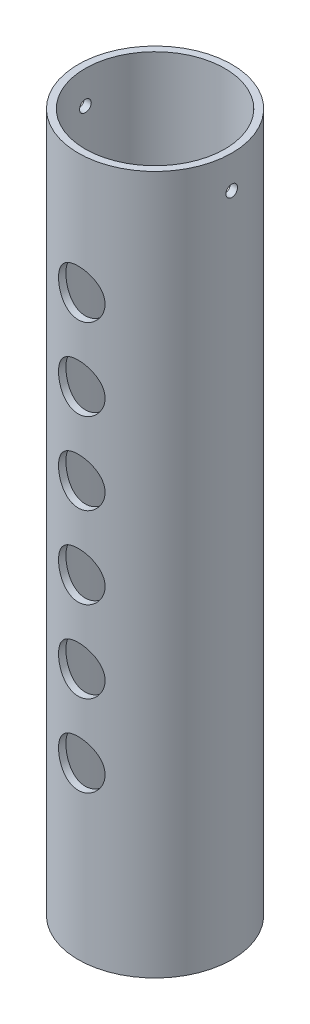
from build123d import *

# Parameters (mm, degrees)
SKETCH1_R               = 33
SKETCH1_R_2             = 30
EXTRUDE_THIN1_DEPTH     = 300
SKETCH2_R               = 10
CUT_EXTRUDE1_DEPTH      = 34
LPATTERN1_COUNT         = 6
LPATTERN1_PITCH         = 35
SKETCH3_R               = 2.5
CUT_EXTRUDE2_DEPTH      = 34.0000001
CUT_EXTRUDE2_DEPTH_BACK = 34.0000001


with BuildPart() as part:
    # Sketch1 → Extrude-Thin1 (new body)
    with BuildSketch(Plane(origin=(0, 0, 0), x_dir=(1, 0, 0), z_dir=(0, 1, 0))):
        Circle(SKETCH1_R)
        Circle(SKETCH1_R_2, mode=Mode.SUBTRACT)
    extrude(amount=EXTRUDE_THIN1_DEPTH)

    # Sketch2 → Cut-Extrude1 (cut, symmetric)
    with BuildSketch(Plane.XY):
        with Locations((0, 248)):
            Circle(SKETCH2_R)
    cut_extrude1 = extrude(amount=CUT_EXTRUDE1_DEPTH, both=True, mode=Mode.SUBTRACT)

    # LPattern1: Cut-Extrude1 ×6
    with Locations(*[(0, -i * LPATTERN1_PITCH, 0) for i in range(1, LPATTERN1_COUNT)]):
        add(cut_extrude1, mode=Mode.SUBTRACT)

    # Sketch3 → Cut-Extrude2 (cut, two sides)
    with BuildSketch(Plane(origin=(0, 0, 0), x_dir=(0, 0, -1), z_dir=(1, 0, 0))) as cut_extrude2_sk:
        with Locations((0, 286)):
            Circle(SKETCH3_R)
    extrude(amount=CUT_EXTRUDE2_DEPTH, mode=Mode.SUBTRACT)
    extrude(cut_extrude2_sk.sketch, amount=-CUT_EXTRUDE2_DEPTH_BACK, mode=Mode.SUBTRACT)


solid = part.part
